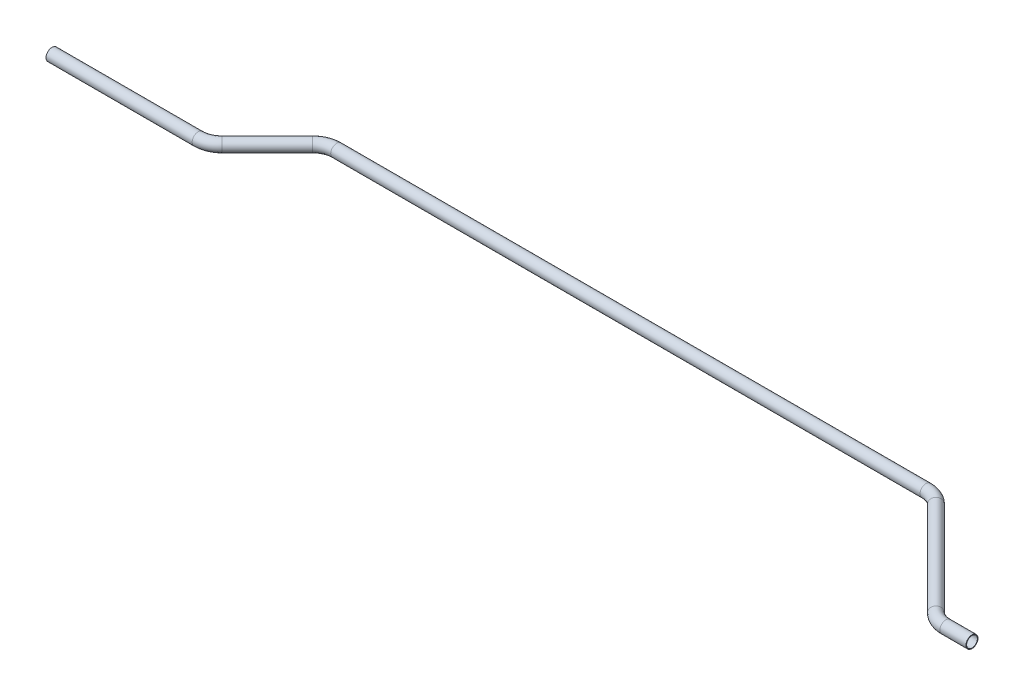
from build123d import *

# Parameters (mm, degrees)
SKETCH2_R   = 6.35
SKETCH2_R_2 = 5.715


with BuildPart() as part:
    # Sweep1: sweep along a path in Sketch1
    with BuildLine(Plane(origin=(0, 0, 0), x_dir=(1, 0, 0), z_dir=(0, 1, 0))) as sweep1_path:
        Line((0, 0), (154.578975516, 0))
        ThreePointArc((154.578975516, 0), (164.299134698, 1.933459874), (172.539487758, 7.439487758))
        Line((172.539487758, 7.439487758), (220.398512242, 55.298512242))
        ThreePointArc((220.398512242, 55.298512242), (228.638865302, 60.804540126), (238.359024484, 62.738))
        Line((238.359024484, 62.738), (861.517480356, 62.738))
        ThreePointArc((861.517480356, 62.738), (871.237639538, 60.804540126), (879.477992598, 55.298512242))
        Line((879.477992598, 55.298512242), (978.899017082, -44.122512242))
        ThreePointArc((978.899017082, -44.122512242), (987.139370142, -49.628540126), (996.859529324, -51.562))
        Line((996.859529324, -51.562), (1024.43850484, -51.562))
    # Sketch2 → Sweep1 (sweep)
    with BuildSketch(Plane(origin=(0, 0, 0), x_dir=(0, 0, -1), z_dir=(1, 0, 0))):
        Circle(SKETCH2_R)
        Circle(SKETCH2_R_2, mode=Mode.SUBTRACT)
    sweep(path=sweep1_path.line)


solid = part.part
